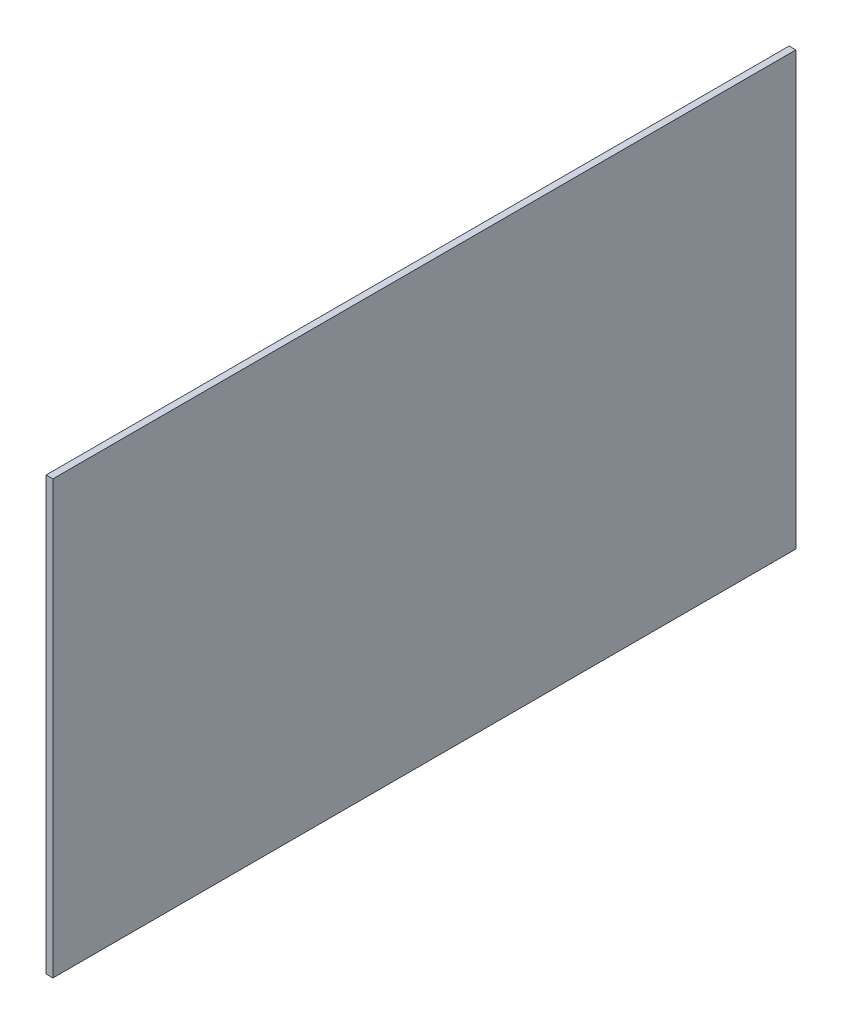
from build123d import *

# Parameters (mm, degrees)
SKETCH1_W           = 698.5
SKETCH1_H           = 406.4
BOSS_EXTRUDE1_DEPTH = 6.35


with BuildPart() as part:
    # Sketch1 → Boss-Extrude1 (new body)
    with BuildSketch(Plane(origin=(0, 0, 0), x_dir=(0, 0, -1), z_dir=(1, 0, 0))):
        Rectangle(SKETCH1_W, SKETCH1_H)
    extrude(amount=BOSS_EXTRUDE1_DEPTH)


solid = part.part
